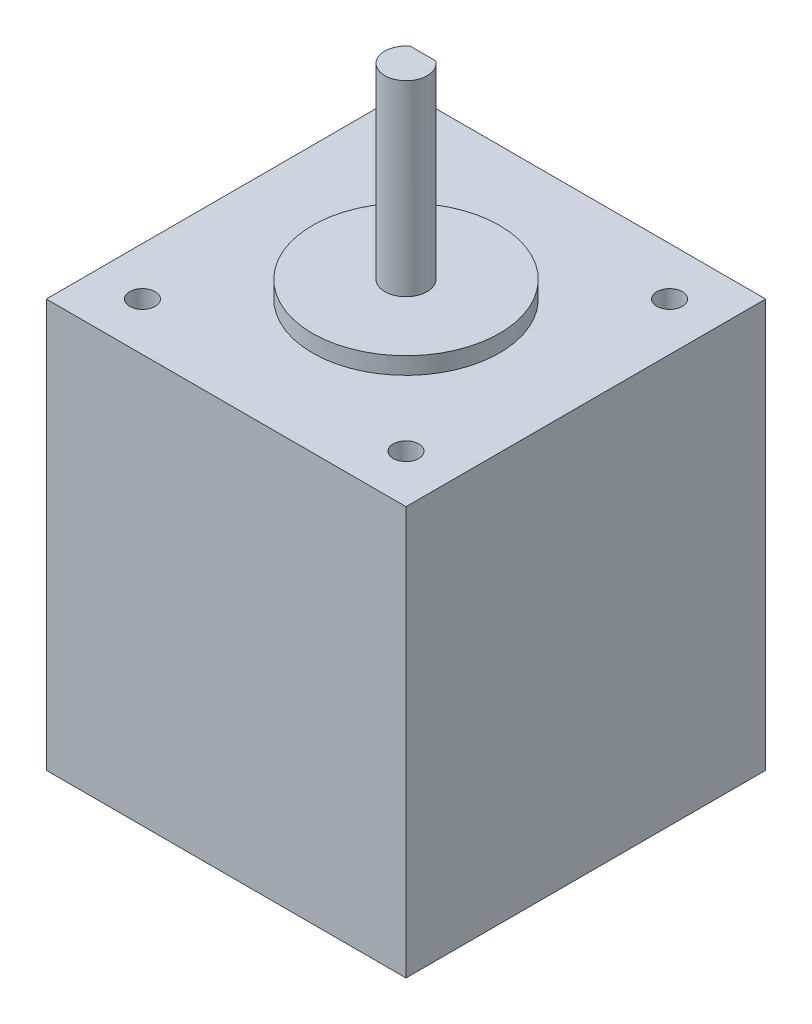
from build123d import *

# Parameters (mm, degrees)
SKETCH1_W           = 42.3
SKETCH1_H           = 42.3
BOSS_EXTRUDE1_DEPTH = 48
SKETCH2_R           = 11
BOSS_EXTRUDE2_DEPTH = 2
SKETCH3_R           = 2.5
BOSS_EXTRUDE3_DEPTH = 24
SKETCH4_R           = 1.5
CUT_EXTRUDE1_DEPTH  = 4
CUT_EXTRUDE2_DEPTH  = 20


with BuildPart() as part:
    # Sketch1 → Boss-Extrude1 (new body)
    with BuildSketch(Plane(origin=(0, 0, 0), x_dir=(1, 0, 0), z_dir=(0, 1, 0))):
        Rectangle(SKETCH1_W, SKETCH1_H)
    extrude(amount=BOSS_EXTRUDE1_DEPTH)

    # Sketch2 → Boss-Extrude2 (add)
    with BuildSketch(Plane(origin=(0, 48, 0), x_dir=(1, 0, 0), z_dir=(0, 1, 0))):
        Circle(SKETCH2_R)
    extrude(amount=BOSS_EXTRUDE2_DEPTH)

    # Sketch3 → Boss-Extrude3 (add)
    with BuildSketch(Plane(origin=(0, 48, 0), x_dir=(1, 0, 0), z_dir=(0, 1, 0))):
        Circle(SKETCH3_R)
    extrude(amount=BOSS_EXTRUDE3_DEPTH)

    # Sketch4 → Cut-Extrude1 (cut)
    with BuildSketch(Plane(origin=(0, 48, 0), x_dir=(1, 0, 0), z_dir=(0, 1, 0))):
        with Locations((15.5, 15.5)):
            Circle(SKETCH4_R)
        with Locations((15.5, -15.5)):
            Circle(SKETCH4_R)
        with Locations((-15.5, 15.5)):
            Circle(SKETCH4_R)
        with Locations((-15.5, -15.5)):
            Circle(SKETCH4_R)
    extrude(amount=-CUT_EXTRUDE1_DEPTH, mode=Mode.SUBTRACT)

    # Sketch5 → Cut-Extrude2 (cut)
    with BuildSketch(Plane(origin=(0, 72, 0), x_dir=(1, 0, 0), z_dir=(0, 1, 0))):
        Polygon((-76.274840795, 2), (-1.5, 2), (1.5, 2), (76.274840795, 2), (76.274840795, 151.54968159), (-76.274840795, 151.54968159), align=None)
    extrude(amount=-CUT_EXTRUDE2_DEPTH, mode=Mode.SUBTRACT)


solid = part.part
